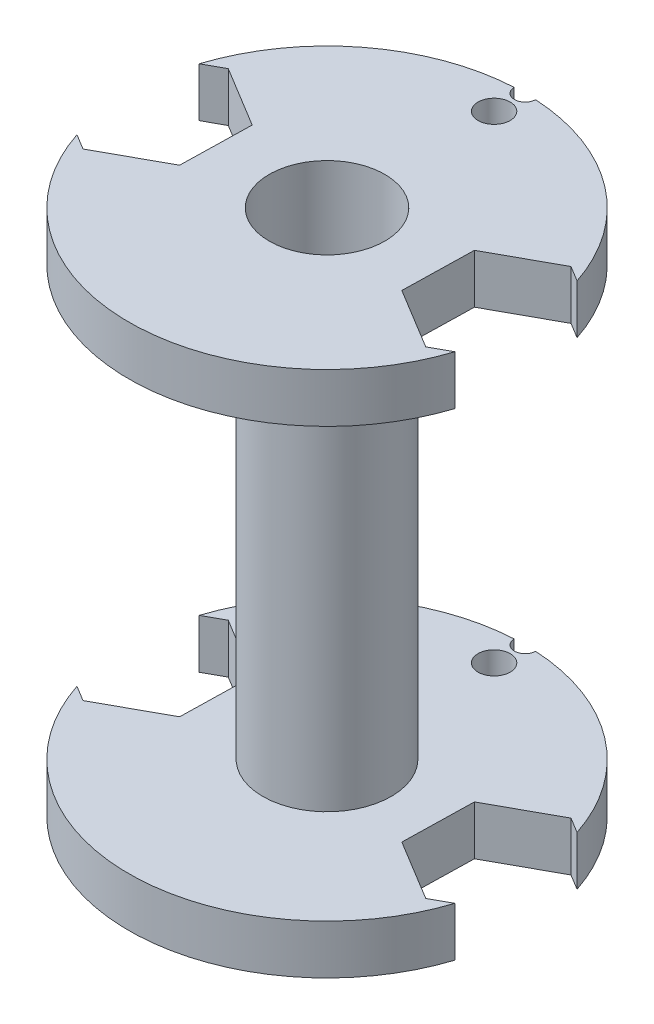
from build123d import *

# Parameters (mm, degrees)
SKETCH1_R           = 9.25
SKETCH1_R_2         = 2.7
BOSS_EXTRUDE1_DEPTH = 2.3
CUT_EXTRUDE3_DEPTH  = 2.5
SKETCH4_R           = 0.75
SKETCH4_R_2         = 0.5
CUT_EXTRUDE4_DEPTH  = 5
SKETCH2_R           = 3
SKETCH2_R_2         = 2.7
BOSS_EXTRUDE2_DEPTH = 10


with BuildPart() as part:
    # Sketch1 → Boss-Extrude1 (new body)
    with BuildSketch(Plane(origin=(0, 0, 0), x_dir=(1, 0, 0), z_dir=(0, 1, 0))):
        Circle(SKETCH1_R)
        Circle(SKETCH1_R_2, mode=Mode.SUBTRACT)
    extrude(amount=BOSS_EXTRUDE1_DEPTH)

    # Sketch3 → Cut-Extrude3 (cut)
    with BuildSketch(Plane.XZ):
        Polygon((-5.161329605, 1.721273866), (-8.071331697, 3.318997608), (-10.910002092, 1.597723742), (-10.838670395, -1.721273866), (-7.928668303, -3.318997608), (-5.089997908, -1.597723742), align=None)
        Polygon((5.161329605, -1.721273866), (8.071331697, -3.318997608), (10.910002092, -1.597723742), (10.838670395, 1.721273866), (7.928668303, 3.318997608), (5.089997908, 1.597723742), align=None)
    extrude(amount=-CUT_EXTRUDE3_DEPTH, mode=Mode.SUBTRACT)

    # Sketch4 → Cut-Extrude4 (cut)
    with BuildSketch(Plane(origin=(0, 2.3, 0), x_dir=(1, 0, 0), z_dir=(0, 1, 0))):
        with Locations((0, 7.8)):
            Circle(SKETCH4_R)
        with Locations((0, 9.25)):
            Circle(SKETCH4_R_2)
    extrude(amount=-CUT_EXTRUDE4_DEPTH, mode=Mode.SUBTRACT)

    # Sketch2 → Boss-Extrude2 (add)
    with BuildSketch(Plane(origin=(0, 2.3, 0), x_dir=(1, 0, 0), z_dir=(0, 1, 0))):
        Circle(SKETCH2_R)
        Circle(SKETCH2_R_2, mode=Mode.SUBTRACT)
    extrude(amount=BOSS_EXTRUDE2_DEPTH)

    # Mirror7: part across plane


with BuildPart() as part_1:
    add(part.part)
    add(part.part.mirror(Plane.ZX.offset(12.3)))


solid = part_1.part
